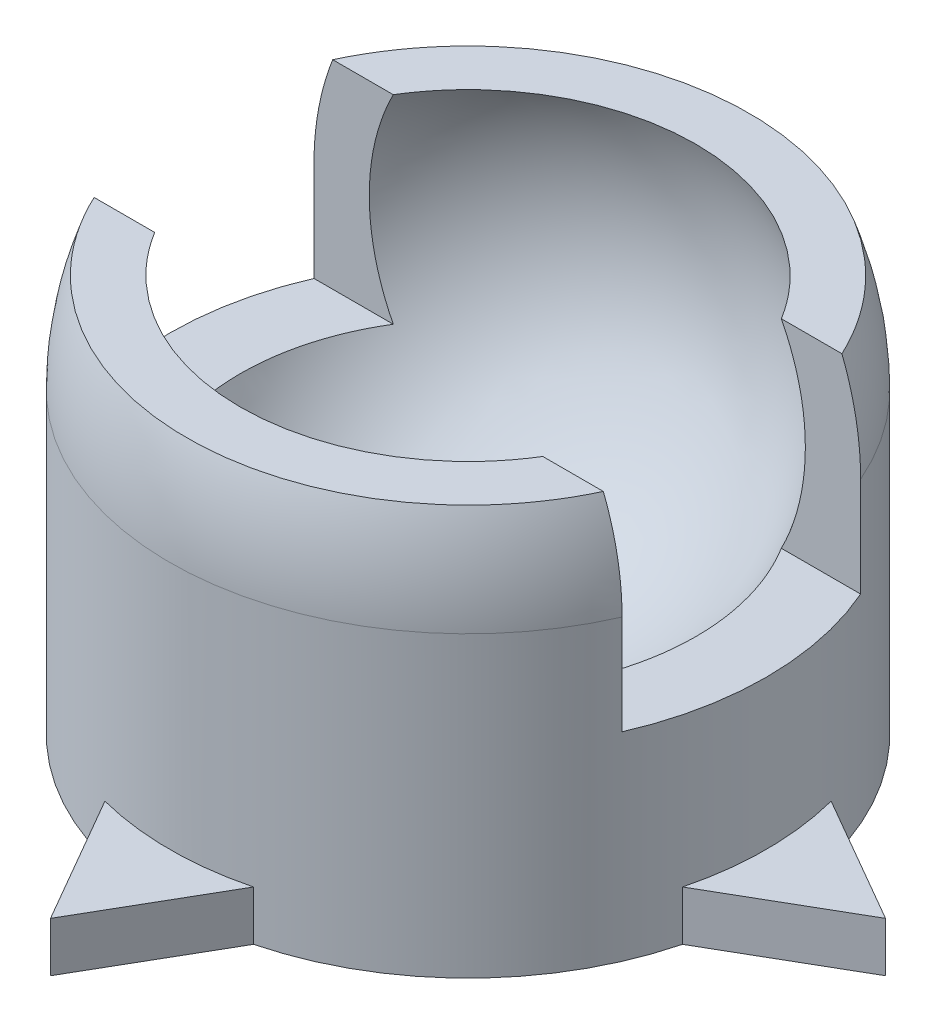
from build123d import *

# Parameters (mm, degrees)
SKETCH9_R           = 7.5
BOSS_EXTRUDE2_DEPTH = 7.5
SKETCH10_W          = 17.888516884
SKETCH10_H          = 18.524036688
CUT_EXTRUDE2_DEPTH  = 20
SKETCH15_W          = 6
SKETCH15_H          = 5
CUT_EXTRUDE3_DEPTH  = 20
BOSS_EXTRUDE4_DEPTH = 1.25
SKETCH24_R          = 1.5
CUT_EXTRUDE4_DEPTH  = 15
BOSS_EXTRUDE5_DEPTH = 1.25


with BuildPart() as part:
    # Sketch7 → Revolve1 (revolve)
    with BuildSketch(Plane(origin=(0, 0, 0), x_dir=(1, 0, 0), z_dir=(0, 1, 0))):
        with BuildLine():
            Line((7.5, 0), (6.25, 0))
            ThreePointArc((6.25, 0), (0, -6.25), (-6.25, 0))
            Line((-6.25, 0), (-7.5, 0))
            ThreePointArc((-7.5, 0), (0, -7.5), (7.5, 0))
        make_face()
    revolve(axis=Axis((-6.25, 0, 0), (-1, 0, 0)))

    # Sketch10 → Cut-Extrude2 (cut)
    with BuildSketch(Plane(origin=(0, 2.5, 0), x_dir=(-1, 0, 0), z_dir=(0, -1, 0))):
        with Locations((-0.350209641, -0.603260139)):
            Rectangle(SKETCH10_W, SKETCH10_H)
    extrude(amount=-CUT_EXTRUDE2_DEPTH, mode=Mode.SUBTRACT)


with BuildPart() as body_2:
    # Sketch9 → Boss-Extrude2 (new body)
    with BuildSketch(Plane(origin=(0, 0, 0), x_dir=(1, 0, 0), z_dir=(0, 1, 0))):
        with Locations(Location((0, 0, 0), (0, 0, 270))):
            Circle(SKETCH9_R)
    extrude(amount=-BOSS_EXTRUDE2_DEPTH)

    # Sketch12 → Cut-Revolve4 (revolve, cut)
    with BuildSketch(Plane(origin=(0, 0, 0), x_dir=(1, 0, 0), z_dir=(0, 1, 0))):
        with BuildLine():
            Line((-6.75, 0), (6.75, 0))
            ThreePointArc((6.75, 0), (0, 6.75), (-6.75, 0))
        make_face()
    revolve(axis=Axis((-8.960272056, 0, 0), (1, 0, 0)), mode=Mode.SUBTRACT)


with BuildPart() as cut_extrude3_tool:
    # Sketch15 → Cut-Extrude3 (new body)
    with BuildSketch(Plane(origin=(7.5, 0, 0), x_dir=(0, 0, -1), z_dir=(1, 0, 0))):
        Rectangle(SKETCH15_W, SKETCH15_H)
    extrude(amount=-CUT_EXTRUDE3_DEPTH)


with BuildPart() as part_1:
    add(part.part)

    # Cut-Extrude3: cut by cut_extrude3_tool
    add(cut_extrude3_tool.part, mode=Mode.SUBTRACT)


with BuildPart() as body_2_1:
    add(body_2.part)

    # Cut-Extrude3: cut by cut_extrude3_tool
    add(cut_extrude3_tool.part, mode=Mode.SUBTRACT)

    # Sketch23 → Boss-Extrude4 (add)
    with BuildSketch(Plane.XZ.offset(7.5)):
        with BuildLine():
            Line((-10.5, 0), (-7.263493829, -1.868597709))
            ThreePointArc((-7.263493829, -1.868597709), (-7.5, 0), (-7.263493829, 1.868597709))
            Line((-7.263493829, 1.868597709), (-10.5, 0))
        make_face()
    boss_extrude4 = extrude(amount=-BOSS_EXTRUDE4_DEPTH)

    # Mirror1: Boss-Extrude4 across plane
    add(boss_extrude4.mirror(Plane(origin=(0, 0, 0), x_dir=(0, 0, 1), z_dir=(1, 0, 0))))


with BuildPart() as cut_extrude4_tool:
    # Sketch24 → Cut-Extrude4 (new body)
    with BuildSketch(Plane.XZ.offset(7.5)):
        with Locations(Location((0, 0, 0), (0, 0, 90))):
            Circle(SKETCH24_R)
    extrude(amount=-CUT_EXTRUDE4_DEPTH)


with BuildPart() as part_2:
    add(part_1.part)

    # Cut-Extrude4: cut by cut_extrude4_tool
    add(cut_extrude4_tool.part, mode=Mode.SUBTRACT)



with BuildPart() as body_2_2:
    add(body_2_1.part)

    # Cut-Extrude4: cut by cut_extrude4_tool
    add(cut_extrude4_tool.part, mode=Mode.SUBTRACT)


with BuildPart() as part_3:
    add(part_2.part)

    add(body_2_2.part)  # Boss-Extrude5 merges body 2
    # Sketch25 → Boss-Extrude5 (add)
    with BuildSketch(Plane.XZ.offset(7.5)):
        with BuildLine():
            Line((0, 10.5), (1.868597709, 7.263493829))
            ThreePointArc((1.868597709, 7.263493829), (0, 7.5), (-1.868597709, 7.263493829))
            Line((-1.868597709, 7.263493829), (0, 10.5))
        make_face()
    boss_extrude5 = extrude(amount=-BOSS_EXTRUDE5_DEPTH)

    # Mirror2: Boss-Extrude5 across plane
    add(boss_extrude5.mirror(Plane.XY))


solid = part_3.part
